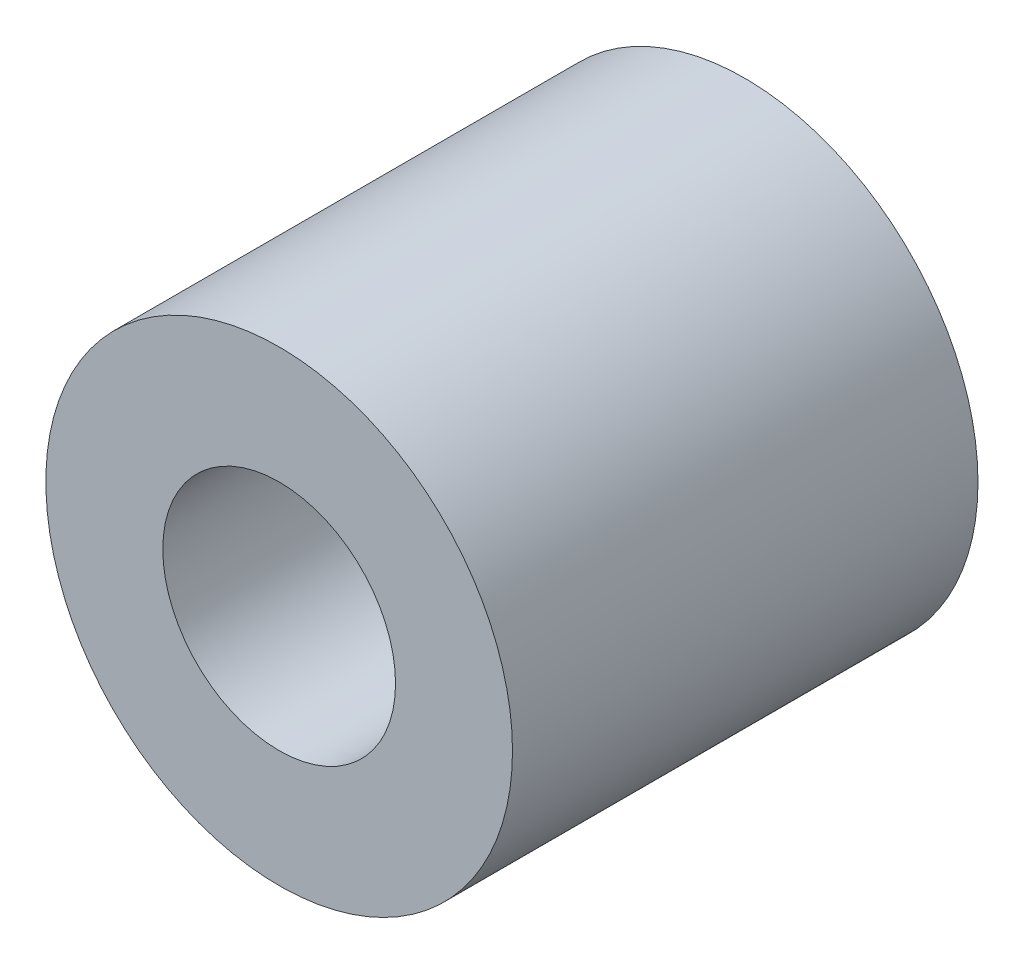
from build123d import *

# Parameters (mm, degrees)
SKETCH1_R           = 4.01
SKETCH1_R_2         = 2
BOSS_EXTRUDE1_DEPTH = 4


with BuildPart() as part:
    # Sketch1 → Boss-Extrude1 (new, symmetric)
    with BuildSketch(Plane.XY):
        Circle(SKETCH1_R)
        Circle(SKETCH1_R_2, mode=Mode.SUBTRACT)
    extrude(amount=BOSS_EXTRUDE1_DEPTH, both=True)


solid = part.part
